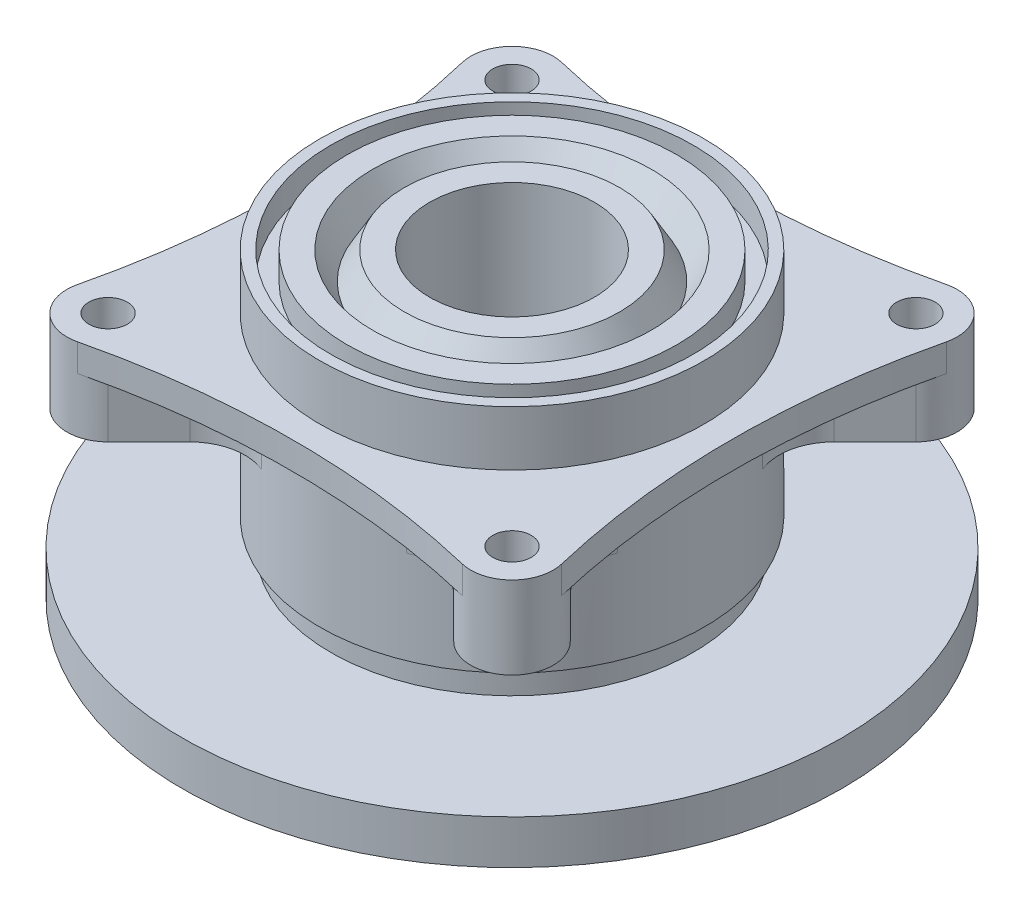
from build123d import *

# Parameters (mm, degrees)
SKETCH3_R                = 35
BOSS_EXTRUDE1_DEPTH      = 5
BOSS_EXTRUDE3_DEPTH      = 10
FILLET1_R                = 10
SKETCH5_R                = 3.5
CUT_EXTRUDE1_DEPTH       = 15
CIRPATTERN1_COUNT        = 4
FILLET1_OF_CIRPATTERN1_R = 10


with BuildPart() as part:
    # Sketch1 → Revolve1 (revolve)
    with BuildSketch(Plane.XY, mode=Mode.PRIVATE) as revolve1_sk:
        Polygon((15, 60), (15, 0), (30, 0), (31.763269807, -10), (36, -10), (37.763269807, 0), (37.763269807, 5), (60, 5), (60, 13), (33, 13), (33, 18), (35, 18), (35, 60), (33, 60), (33, 55), (30, 55), (30, 60), (25.386751346, 60), (22.5, 55), (19.613248654, 60), align=None)
    revolve(revolve1_sk.sketch.rotate(Axis((0, 25.612491422, 0), (0, -1, 0)), 180), axis=Axis((0, 25.612491422, 0), (0, -1, 0)))  # turned: the seam where the file's is

    # Sketch3 → Boss-Extrude1 (add)
    with BuildSketch(Plane(origin=(0, 50, 0), x_dir=(1, 0, 0), z_dir=(0, 1, 0))):
        with BuildLine():
            ThreePointArc((44.062305213, 35.018621544), (42.072853481, 42.072853481), (35.018621544, 44.062305213))
            ThreePointArc((35.018621544, 44.062305213), (0, 39.917357046), (-35.018621544, 44.062305213))
            ThreePointArc((-35.018621544, 44.062305213), (-42.072853481, 42.072853481), (-44.062305213, 35.018621544))
            ThreePointArc((-44.062305213, 35.018621544), (-39.917357046, 0), (-44.062305213, -35.018621544))
            ThreePointArc((-44.062305213, -35.018621544), (-42.072853481, -42.072853481), (-35.018621544, -44.062305213))
            ThreePointArc((-35.018621544, -44.062305213), (0, -39.917357046), (35.018621544, -44.062305213))
            ThreePointArc((35.018621544, -44.062305213), (42.072853481, -42.072853481), (44.062305213, -35.018621544))
            ThreePointArc((44.062305213, -35.018621544), (39.917357046, 0), (44.062305213, 35.018621544))
        make_face()
        with Locations(Location((0, 0, 0), (0, 0, 180))):  # turned: the seam where the file's is
            Circle(SKETCH3_R, mode=Mode.SUBTRACT)
    extrude(amount=-BOSS_EXTRUDE1_DEPTH)

    # Sketch4 → Boss-Extrude3 (add)
    with BuildSketch(Plane.XZ.offset(-45)):
        with BuildLine():
            Line((29.477150366, 18.870548648), (42.072853481, 31.466251763))
            ThreePointArc((42.072853481, 31.466251763), (42.072853481, 42.072853481), (31.466251763, 42.072853481))
            Line((31.466251763, 42.072853481), (18.870548648, 29.477150366))
            ThreePointArc((18.870548648, 29.477150366), (24.748737342, 24.748737342), (29.477150366, 18.870548648))
        make_face()
    boss_extrude3 = extrude(amount=BOSS_EXTRUDE3_DEPTH)

    # Fillet1
    fillet1_edges = [part.edges().sort_by_distance(p)[0] for p in [
        (18.870548648, 40, 29.477150366),
        (29.477150366, 40, 18.870548648),
    ]]
    fillet(fillet1_edges, radius=FILLET1_R)

    # Sketch5 → Cut-Extrude1 (cut)
    with BuildSketch(Plane(origin=(0, 50, 0), x_dir=(1, 0, 0), z_dir=(0, 1, 0))):
        with Locations(Location((36.769552622, -36.769552622, 0), (0, 0, 180))):  # turned: the seam where the file's is
            Circle(SKETCH5_R)
    cut_extrude1 = extrude(amount=-CUT_EXTRUDE1_DEPTH, mode=Mode.SUBTRACT)

    # CirPattern1: Boss-Extrude3, Cut-Extrude1 ×4 about axis
    cirpattern1_axis = Axis((0, 0, 0), (0, 1, 0))
    add([boss_extrude3.rotate(cirpattern1_axis, i * 360 / CIRPATTERN1_COUNT) for i in range(1, CIRPATTERN1_COUNT)])
    add([cut_extrude1.rotate(cirpattern1_axis, i * 360 / CIRPATTERN1_COUNT) for i in range(1, CIRPATTERN1_COUNT)], mode=Mode.SUBTRACT)

    # Fillet1 of CirPattern1
    fillet1_of_cirpattern1_edges = [part.edges().sort_by_distance(p)[0] for p in [
        (29.477150366, 40, -18.870548648),
        (18.870548648, 40, -29.477150366),
        (-18.870548648, 40, -29.477150366),
        (-29.477150366, 40, -18.870548648),
        (-29.477150366, 40, 18.870548648),
        (-18.870548648, 40, 29.477150366),
    ]]
    fillet(fillet1_of_cirpattern1_edges, radius=FILLET1_OF_CIRPATTERN1_R)


solid = part.part
